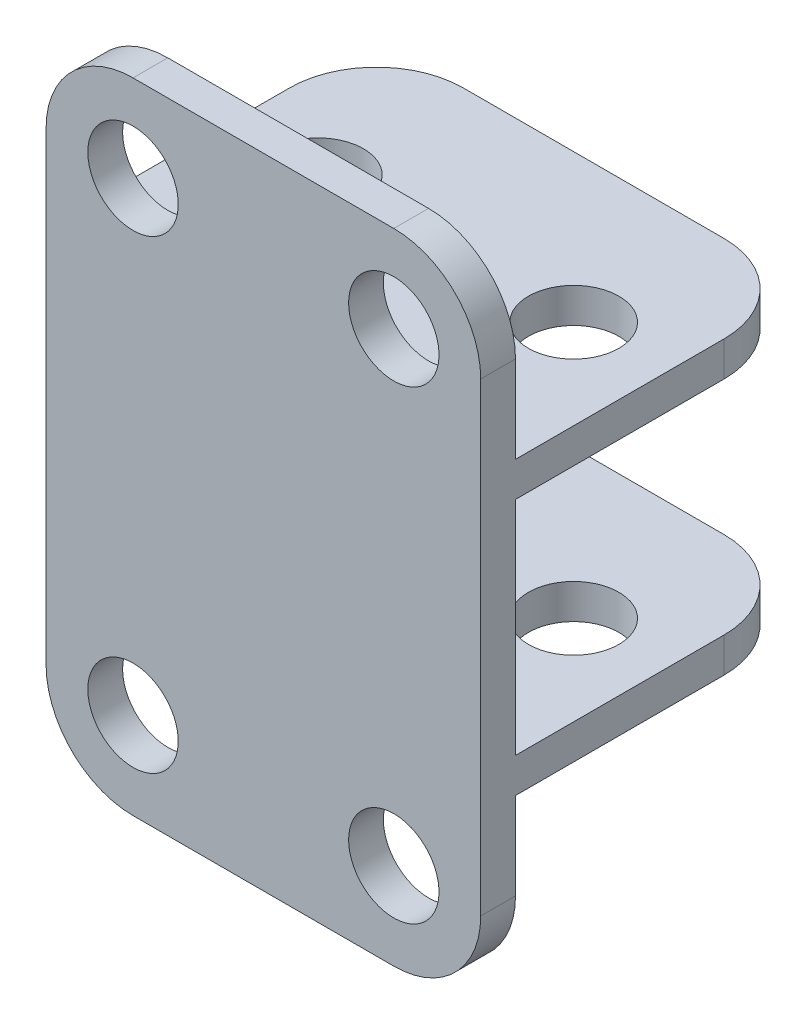
from build123d import *

# Parameters (mm, degrees)
SKETCH1_W           = 25
SKETCH1_H           = 17
SKETCH1_R           = 2.6
BOSS_EXTRUDE1_DEPTH = 2
SKETCH2_W           = 25
SKETCH2_H           = 14.75
BOSS_EXTRUDE2_DEPTH = 2
SKETCH3_W           = 25
SKETCH3_H           = 2
BOSS_EXTRUDE3_DEPTH = 10
FILLET1_R           = 5
SKETCH4_R           = 2.6
CUT_EXTRUDE1_DEPTH  = 10


with BuildPart() as part:
    # Sketch1 → Boss-Extrude1 (new body)
    with BuildSketch(Plane(origin=(0, 0, 0), x_dir=(1, 0, 0), z_dir=(0, 1, 0))):
        Rectangle(SKETCH1_W, SKETCH1_H)
        with Locations((-7.345, 0)):
            Circle(SKETCH1_R, mode=Mode.SUBTRACT)
        with Locations((7.345, 0)):
            Circle(SKETCH1_R, mode=Mode.SUBTRACT)
    extrude(amount=BOSS_EXTRUDE1_DEPTH)

    # Sketch2 → Boss-Extrude2 (add)
    with BuildSketch(Plane.XY.offset(8.5)):
        with Locations((0, 7.375)):
            Rectangle(SKETCH2_W, SKETCH2_H)
    extrude(amount=BOSS_EXTRUDE2_DEPTH)

    # Mirror2: part across plane


with BuildPart() as part_1:
    add(part.part)
    add(part.part.mirror(Plane.ZX.offset(8.375)))

    # Sketch3 → Boss-Extrude3 (add)
    with BuildSketch(Plane(origin=(0, 16.75, 0), x_dir=(1, 0, 0), z_dir=(0, 1, 0))):
        with Locations((0, -9.5)):
            Rectangle(SKETCH3_W, SKETCH3_H)
    extrude(amount=BOSS_EXTRUDE3_DEPTH)

    # Mirror3: part across plane


with BuildPart() as part_2:
    add(part_1.part)
    add(part_1.part.mirror(Plane.ZX.offset(8.375)))

    # Fillet1
    fillet1_edges = [part_2.edges().sort_by_distance(p)[0] for p in [
        (12.5, 15.75, -8.5),
        (-12.5, 15.75, -8.5),
        (-12.5, 26.75, 9.5),
        (12.5, 26.75, 9.5),
        (-12.5, 1, -8.5),
        (12.5, 1, -8.5),
        (-12.5, -10, 9.5),
        (12.5, -10, 9.5),
    ]]
    fillet(fillet1_edges, radius=FILLET1_R)

    # Sketch4 → Cut-Extrude1 (cut)
    with BuildSketch(Plane(origin=(0, 0, 8.5), x_dir=(-1, 0, 0), z_dir=(0, 0, -1))):
        with Locations((-7.5, 21.75)):
            Circle(SKETCH4_R)
        with Locations((7.5, 21.75)):
            Circle(SKETCH4_R)
        with Locations((7.5, -5)):
            Circle(SKETCH4_R)
        with Locations((-7.5, -5)):
            Circle(SKETCH4_R)
    extrude(amount=-CUT_EXTRUDE1_DEPTH, mode=Mode.SUBTRACT)


solid = part_2.part
